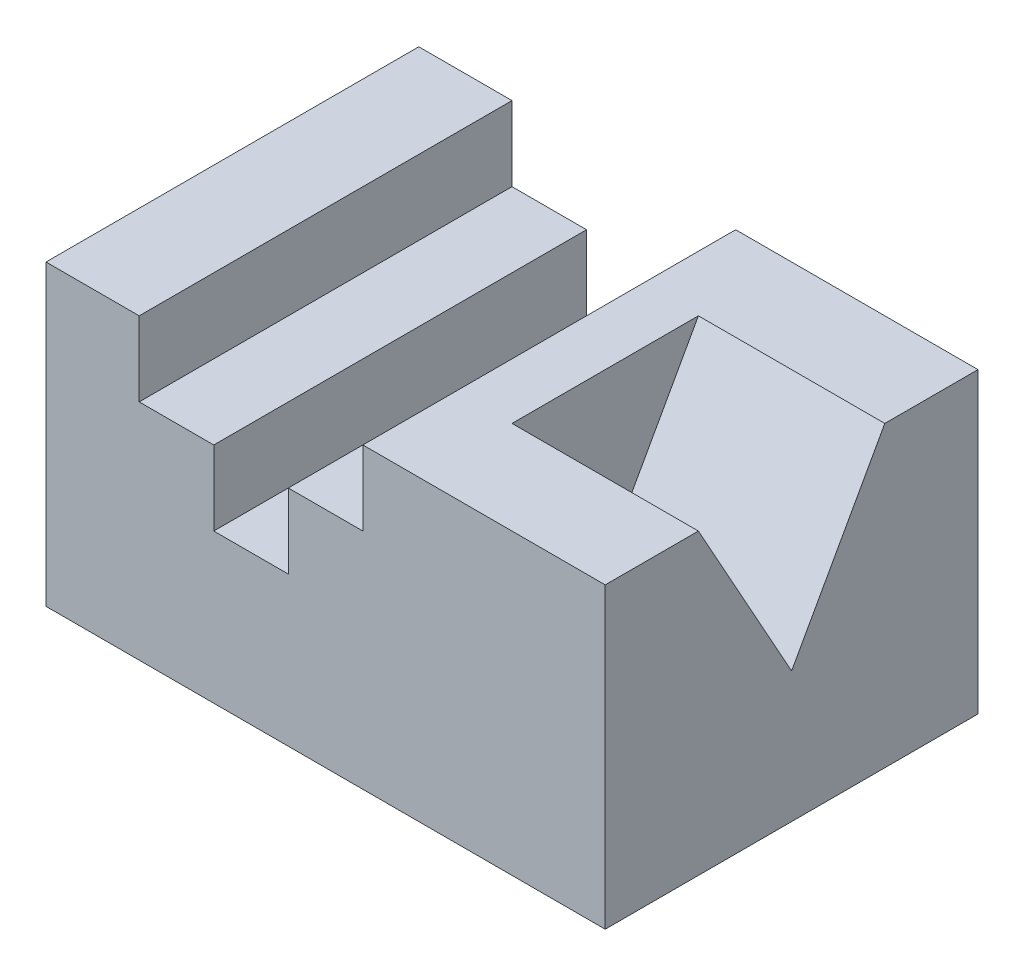
from build123d import *

# Parameters (mm, degrees)
SKETCH1_W               = 150
SKETCH1_H               = 100
BOSS_EXTRUDE1_DEPTH     = 80
CUT_EXTRUDE1_DEPTH      = 50
CUT_EXTRUDE2_DEPTH      = 1
CUT_EXTRUDE2_DEPTH_BACK = 101


with BuildPart() as part:
    # Sketch1 → Boss-Extrude1 (new body)
    with BuildSketch(Plane(origin=(0, 0, 0), x_dir=(1, 0, 0), z_dir=(0, 1, 0))):
        Rectangle(SKETCH1_W, SKETCH1_H)
    extrude(amount=BOSS_EXTRUDE1_DEPTH)

    # Sketch2 → Cut-Extrude1 (cut)
    with BuildSketch(Plane(origin=(75, 0, 0), x_dir=(0, 0, -1), z_dir=(1, 0, 0))):
        Polygon((-25, 80), (25, 80), (0, 35), align=None)
    extrude(amount=-CUT_EXTRUDE1_DEPTH, mode=Mode.SUBTRACT)

    # Sketch3 → Cut-Extrude2 (cut, two sides)
    with BuildSketch(Plane.XY.offset(50)) as cut_extrude2_sk:
        Polygon((-425, 80), (-75, 80), (-50, 80), (-50, 60), (-30, 60), (-30, 40), (-10, 40), (-10, 60), (10, 60), (10, 80), (10, 430), (-428.813790469, 975.382853869), (-863.813790469, 625.382853869), align=None)
    extrude(amount=CUT_EXTRUDE2_DEPTH, mode=Mode.SUBTRACT)
    extrude(cut_extrude2_sk.sketch, amount=-CUT_EXTRUDE2_DEPTH_BACK, mode=Mode.SUBTRACT)


solid = part.part
